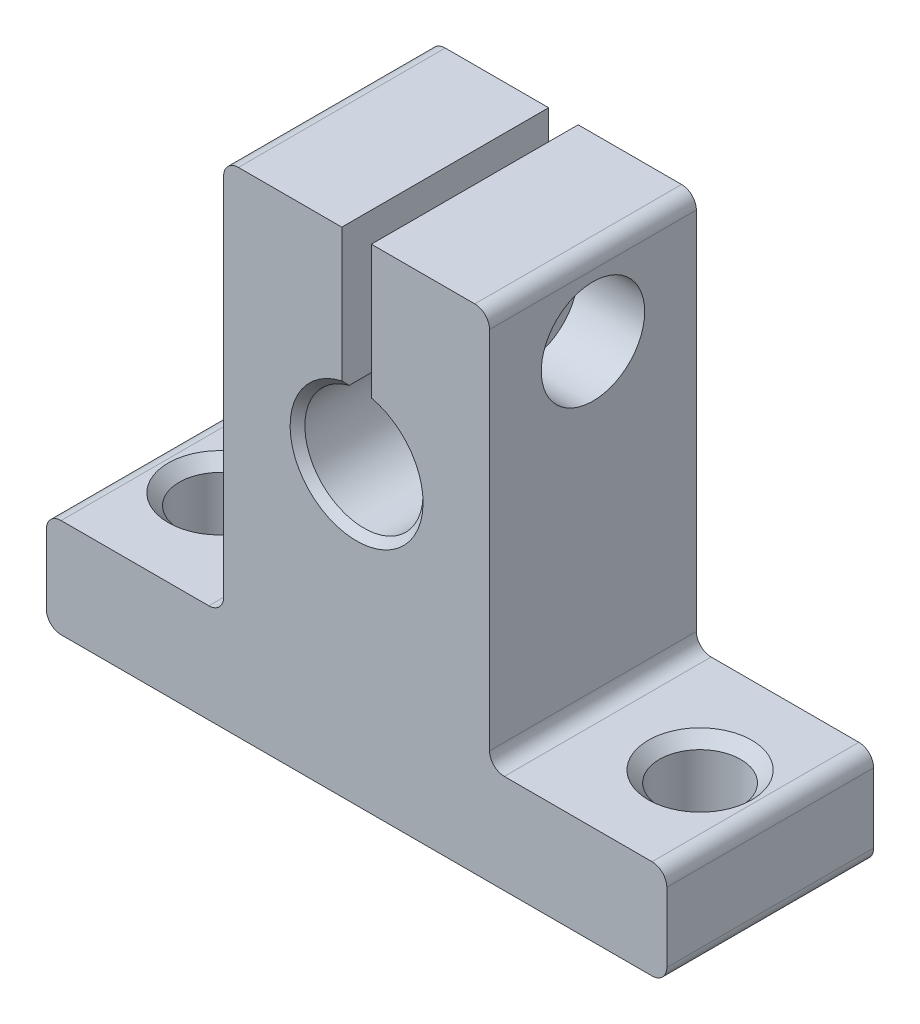
from build123d import *

# Parameters (mm, degrees)
BOSS_EXTRUDE1_DEPTH                     = 14
FILLET1_R                               = 1
CBORE_FOR_M5_HEX_HEAD_BOLT1_D           = 4
CBORE_FOR_M5_HEX_HEAD_BOLT1_DEPTH       = 8
CBORE_FOR_M5_HEX_HEAD_BOLT1_CBORE_D     = 7
CBORE_FOR_M5_HEX_HEAD_BOLT1_CBORE_DEPTH = 4.5
M5_TAPPED_HOLE1_D                       = 3.5
M5_TAPPED_HOLE1_DEPTH                   = 8
M5_TAPPED_HOLE1_CSINK_D                 = 5.5
M5_TAPPED_HOLE1_CSINK_ANGLE             = 90
CHAMFER1_SIZE                           = 0.5


with BuildPart() as part:
    # Sketch1 → Boss-Extrude1 (new body)
    with BuildSketch(Plane.XY):
        with BuildLine():
            Line((-21, -20), (21, -20))
            Line((21, -20), (21, -13.3))
            Line((21, -13.3), (9, -13.3))
            Line((9, -13.3), (9, 13.4))
            Line((9, 13.4), (1, 13.4))
            Line((1, 13.4), (1, 3.872983346))
            ThreePointArc((1, 3.872983346), (0, -4), (-1, 3.872983346))
            Line((-1, 3.872983346), (-1, 13.4))
            Line((-1, 13.4), (-9, 13.4))
            Line((-9, 13.4), (-9, -13.3))
            Line((-9, -13.3), (-21, -13.3))
            Line((-21, -13.3), (-21, -20))
        make_face()
    extrude(amount=BOSS_EXTRUDE1_DEPTH)

    # Fillet1
    fillet1_edges = [part.edges().sort_by_distance(p)[0] for p in [
        (-21, -13.3, 7),
        (-9, -13.3, 7),
        (-9, 13.4, 7),
        (9, 13.4, 7),
        (9, -13.3, 7),
        (21, -13.3, 7),
        (21, -20, 7),
        (-21, -20, 7),
    ]]
    fillet(fillet1_edges, radius=FILLET1_R)

    # CBORE for M5 Hex Head Bolt1
    with Locations(Plane(origin=(9, 0, 0), x_dir=(0, 0, -1), z_dir=(1, 0, 0))):
        with Locations((-7, 8.2)):
            CounterBoreHole(CBORE_FOR_M5_HEX_HEAD_BOLT1_D / 2, CBORE_FOR_M5_HEX_HEAD_BOLT1_CBORE_D / 2, CBORE_FOR_M5_HEX_HEAD_BOLT1_CBORE_DEPTH, depth=CBORE_FOR_M5_HEX_HEAD_BOLT1_DEPTH)

    # M5 Tapped Hole1
    with Locations(Plane.ZY.offset(9)):
        with Locations((7, 8.2)):
            CounterSinkHole(M5_TAPPED_HOLE1_D / 2, M5_TAPPED_HOLE1_CSINK_D / 2, depth=M5_TAPPED_HOLE1_DEPTH, counter_sink_angle=M5_TAPPED_HOLE1_CSINK_ANGLE)

    # Sketch8 → CSK for M5 Countersunk Flat Head Screw2 (revolve, cut)
    with BuildSketch(Plane(origin=(16.25, -13.3, 7), x_dir=(0, 0, 1), z_dir=(1, 0, 0))):
        Polygon((0, 0), (0, 6.7), (3.5, 6.7), (2.75, 5.95), (2.75, 0.75), (3.5, 0), align=None)
    revolve(axis=Axis((16.25, -6.95, 7), (0, -1, 0)), mode=Mode.SUBTRACT)

    # Sketch10 → CSK for M5 Countersunk Flat Head Screw3 (revolve, cut)
    with BuildSketch(Plane(origin=(-16.25, -13.3, 7), x_dir=(0, 0, 1), z_dir=(1, 0, 0))):
        Polygon((0, 0), (0, 6.7), (3.5, 6.7), (2.75, 5.95), (2.75, 0.75), (3.5, 0), align=None)
    revolve(axis=Axis((-16.25, -6.95, 7), (0, -1, 0)), mode=Mode.SUBTRACT)

    # Chamfer1
    chamfer1_edges = [part.edges().sort_by_distance(p)[0] for p in [
        (0, -4, 0),
        (0, -4, 14),
    ]]
    chamfer(chamfer1_edges, length=CHAMFER1_SIZE)


solid = part.part
